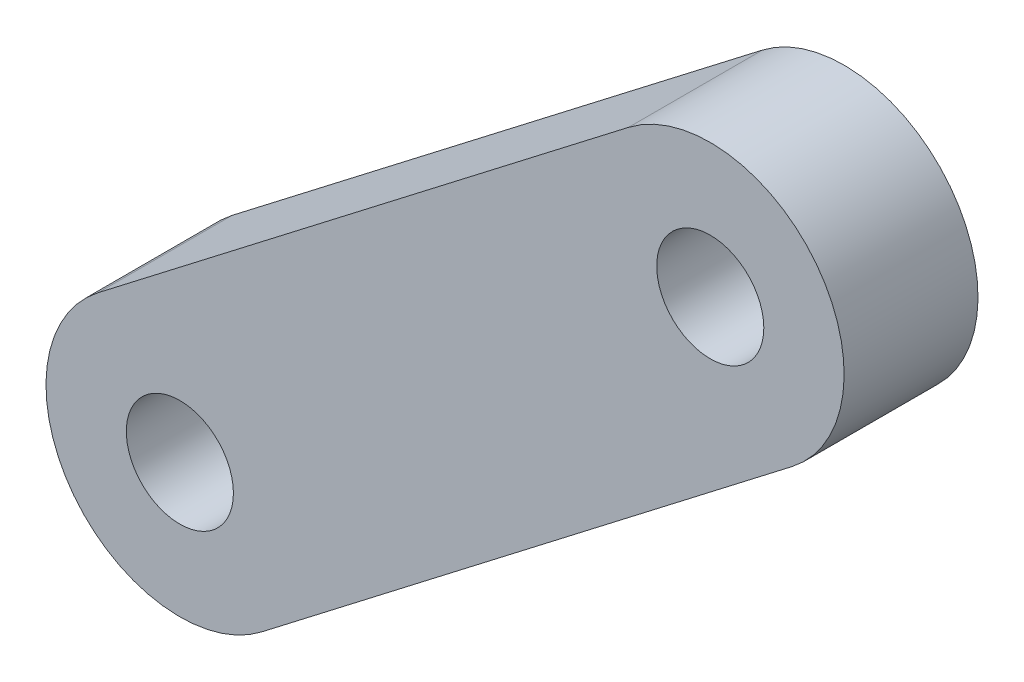
from build123d import *

# Parameters (mm, degrees)
SKETCH1_R           = 2
BOSS_EXTRUDE1_DEPTH = 5


with BuildPart() as part:
    # Sketch1 → Boss-Extrude1 (new body)
    with BuildSketch(Plane(origin=(0, 0, 0), x_dir=(0.999757303, -0.022030336, 0), z_dir=(0, 0, 1))):
        with BuildLine():
            Line((-49.372163993, 87.590629426), (-29.904437649, 103.275259833))
            ThreePointArc((-29.904437649, 103.275259833), (-22.873966299, 102.518640646), (-23.630585486, 95.488169295))
            Line((-23.630585486, 95.488169295), (-43.09831183, 79.803538889))
            ThreePointArc((-43.09831183, 79.803538889), (-50.12878318, 80.560158076), (-49.372163993, 87.590629426))
        make_face()
        with Locations((-26.767511567, 99.381714564)):
            Circle(SKETCH1_R, mode=Mode.SUBTRACT)
        with Locations((-46.235237911, 83.697084158)):
            Circle(SKETCH1_R, mode=Mode.SUBTRACT)
    extrude(amount=BOSS_EXTRUDE1_DEPTH)


solid = part.part
